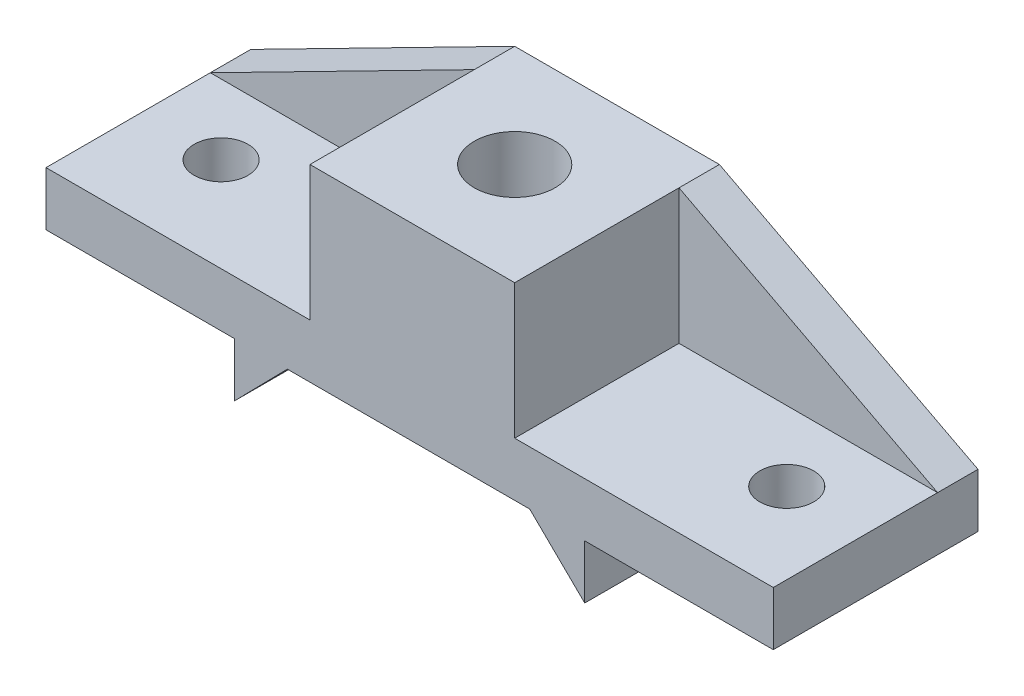
from build123d import *

# Parameters (mm, degrees)
BOSS_EXTRUDE1_DEPTH = 76
CUT_EXTRUDE1_DEPTH  = 61
SKETCH7_R           = 15
SKETCH7_R_2         = 10
CUT_EXTRUDE4_DEPTH  = 71


with BuildPart() as part:
    # Sketch2 → Boss-Extrude1 (new body)
    with BuildSketch(Plane.XY):
        Polygon((155.98455698, -34.815353078), (57.98455698, -84.815353078), (57.98455698, -104.815353078), (127.98455698, -104.815353078), (127.98455698, -124.815353078), (147.58455698, -104.815353078), (237.576393715, -104.815353078), (257.98455698, -124.815353078), (257.98455698, -104.815353078), (327.98455698, -104.815353078), (327.98455698, -84.815353078), (231.98455698, -34.815353078), align=None)
    extrude(amount=BOSS_EXTRUDE1_DEPTH)

    # Sketch5 → Cut-Extrude1 (cut)
    with BuildSketch(Plane.XY.offset(76)):
        Polygon((155.98455698, -34.815353078), (155.98455698, -84.815353078), (57.98455698, -84.815353078), align=None)
        Polygon((231.98455698, -34.815353078), (231.98455698, -84.815353078), (327.98455698, -84.815353078), align=None)
    extrude(amount=-CUT_EXTRUDE1_DEPTH, mode=Mode.SUBTRACT)

    # Sketch7 → Cut-Extrude4 (cut, through all)
    with BuildSketch(Plane(origin=(0, -104.815353078, 0), x_dir=(1, 0, 0), z_dir=(0, 1, 0))):
        with Locations((193.98455698, -38)):
            Circle(SKETCH7_R)
        with Locations((87.98455698, -41)):
            Circle(SKETCH7_R_2)
        with Locations((297.98455698, -41)):
            Circle(SKETCH7_R_2)
    extrude(amount=CUT_EXTRUDE4_DEPTH, mode=Mode.SUBTRACT)


solid = part.part
